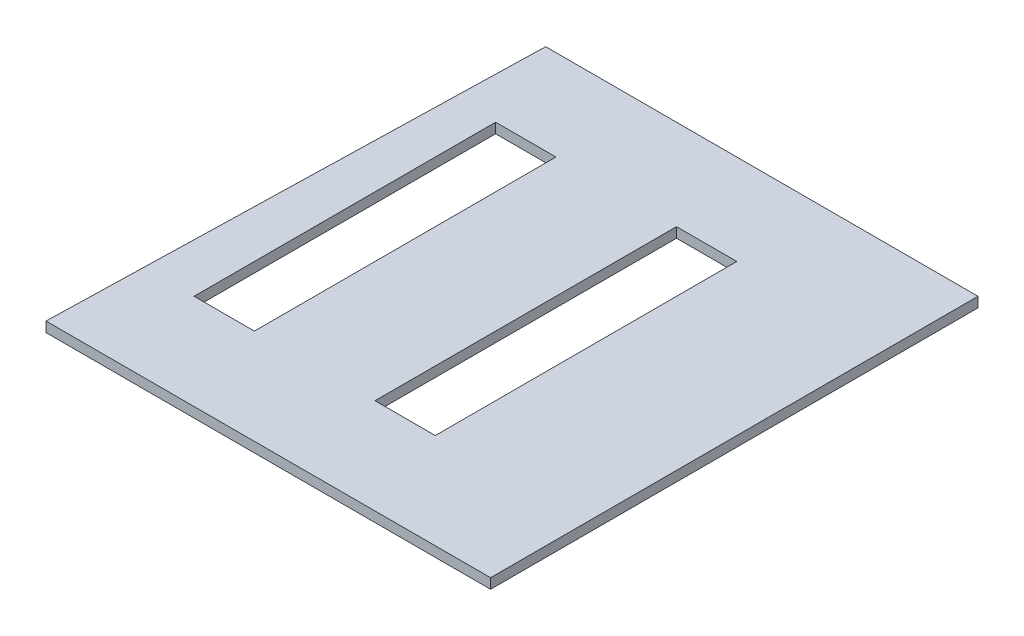
from build123d import *

# Parameters (mm, degrees)
BOSS_EXTRUDE1_DEPTH = 50.8
SKETCH2_W           = 304.8
SKETCH2_H           = 1524
CUT_EXTRUDE1_DEPTH  = 50.8


with BuildPart() as part:
    # Sketch1 → Boss-Extrude1 (new body)
    with BuildSketch(Plane(origin=(0, 0, 0), x_dir=(1, 0, 0), z_dir=(0, 1, 0))):
        Polygon((-1123.713423308, -1232.058348151), (-1061.737423308, 1231.741651849), (1123.424576692, 1231.741651849), (1123.424576692, -1232.058348151), align=None)
    extrude(amount=BOSS_EXTRUDE1_DEPTH)

    # Sketch2 → Cut-Extrude1 (cut)
    with BuildSketch(Plane(origin=(0, 50.8, 0), x_dir=(1, 0, 0), z_dir=(0, 1, 0))):
        with Locations((209.024576692, 12.541651849)):
            Rectangle(SKETCH2_W, SKETCH2_H)
        with Locations((-705.375423308, 12.541651849)):
            Rectangle(SKETCH2_W, SKETCH2_H)
    extrude(amount=-CUT_EXTRUDE1_DEPTH, mode=Mode.SUBTRACT)


solid = part.part
